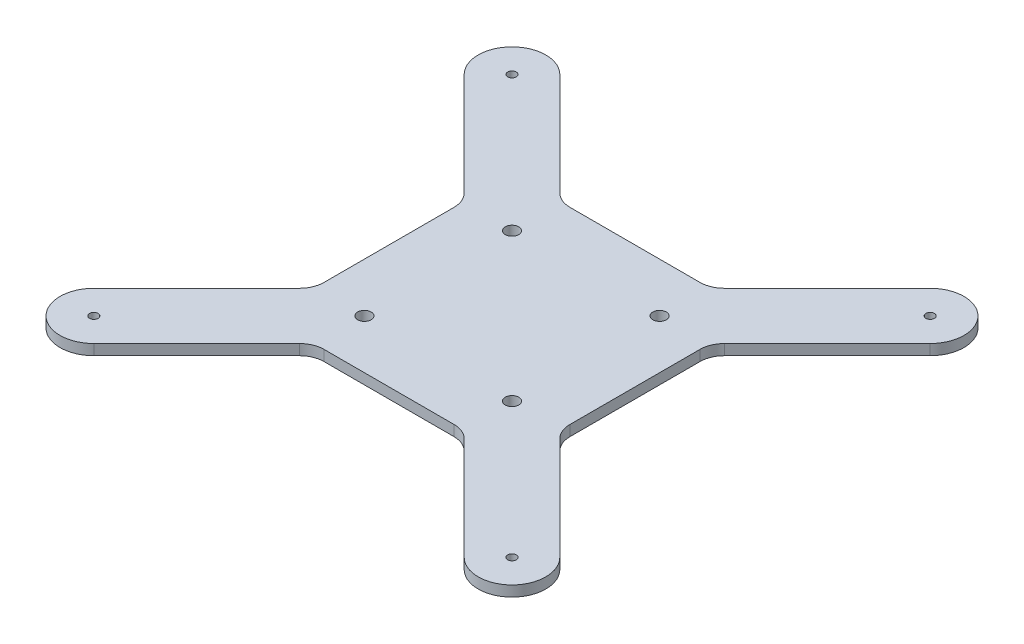
from build123d import *

# Parameters (mm, degrees)
SKETCH1_W           = 100
SKETCH1_H           = 100
SKETCH1_R           = 2.75
BOSS_EXTRUDE1_DEPTH = 4.3
SKETCH2_R           = 1.75
BOSS_EXTRUDE2_DEPTH = 4.3
FILLET1_R           = 10


with BuildPart() as part:
    # Sketch1 → Boss-Extrude1 (new body)
    with BuildSketch(Plane(origin=(0, 0, 0), x_dir=(1, 0, 0), z_dir=(0, 1, 0))):
        with Locations((50, 50)):
            Rectangle(SKETCH1_W, SKETCH1_H)
        with Locations((20, 80)):
            Circle(SKETCH1_R, mode=Mode.SUBTRACT)
        with Locations((80, 80)):
            Circle(SKETCH1_R, mode=Mode.SUBTRACT)
        with Locations((80, 20)):
            Circle(SKETCH1_R, mode=Mode.SUBTRACT)
        with Locations((20, 20)):
            Circle(SKETCH1_R, mode=Mode.SUBTRACT)
    extrude(amount=BOSS_EXTRUDE1_DEPTH)

    # Sketch2 → Boss-Extrude2 (add)
    with BuildSketch(Plane(origin=(0, 4.3, 0), x_dir=(1, 0, 0), z_dir=(0, 1, 0))):
        with BuildLine():
            Line((0, 80.554563517), (-44.722718241, 125.277281759))
            ThreePointArc((-44.722718241, 125.277281759), (-44.722718241, 144.722718241), (-25.277281759, 144.722718241))
            Line((-25.277281759, 144.722718241), (19.445436483, 100))
            Line((19.445436483, 100), (0, 100))
            Line((0, 100), (0, 80.554563517))
        make_face()
        with Locations((-35, 135)):
            Circle(SKETCH2_R, mode=Mode.SUBTRACT)
        with BuildLine():
            Line((100, 100), (100, 80.554563517))
            Line((100, 80.554563517), (144.722718241, 125.277281759))
            ThreePointArc((144.722718241, 125.277281759), (144.722718241, 144.722718241), (125.277281759, 144.722718241))
            Line((125.277281759, 144.722718241), (80.554563517, 100))
            Line((80.554563517, 100), (100, 100))
        make_face()
        with Locations((135, 135)):
            Circle(SKETCH2_R, mode=Mode.SUBTRACT)
        with BuildLine():
            Line((100, 0), (80.554563517, 0))
            Line((80.554563517, 0), (125.277281759, -44.722718241))
            ThreePointArc((125.277281759, -44.722718241), (144.722718241, -44.722718241), (144.722718241, -25.277281759))
            Line((144.722718241, -25.277281759), (100, 19.445436483))
            Line((100, 19.445436483), (100, 0))
        make_face()
        with Locations((135, -35)):
            Circle(SKETCH2_R, mode=Mode.SUBTRACT)
        with BuildLine():
            Line((0, 0), (0, 19.445436483))
            Line((0, 19.445436483), (-44.722718241, -25.277281759))
            ThreePointArc((-44.722718241, -25.277281759), (-44.722718241, -44.722718241), (-25.277281759, -44.722718241))
            Line((-25.277281759, -44.722718241), (19.445436483, 0))
            Line((19.445436483, 0), (0, 0))
        make_face()
        with Locations((-35, -35)):
            Circle(SKETCH2_R, mode=Mode.SUBTRACT)
    extrude(amount=-BOSS_EXTRUDE2_DEPTH)

    # Fillet1
    fillet1_edges = [part.edges().sort_by_distance(p)[0] for p in [
        (0, 2.15, -80.554563517),
        (19.445436483, 2.15, -100),
        (80.554563517, 2.15, -100),
        (100, 2.15, -80.554563517),
        (100, 2.15, -19.445436483),
        (80.554563517, 2.15, 0),
        (19.445436483, 2.15, 0),
        (0, 2.15, -19.445436483),
    ]]
    fillet(fillet1_edges, radius=FILLET1_R)


solid = part.part
